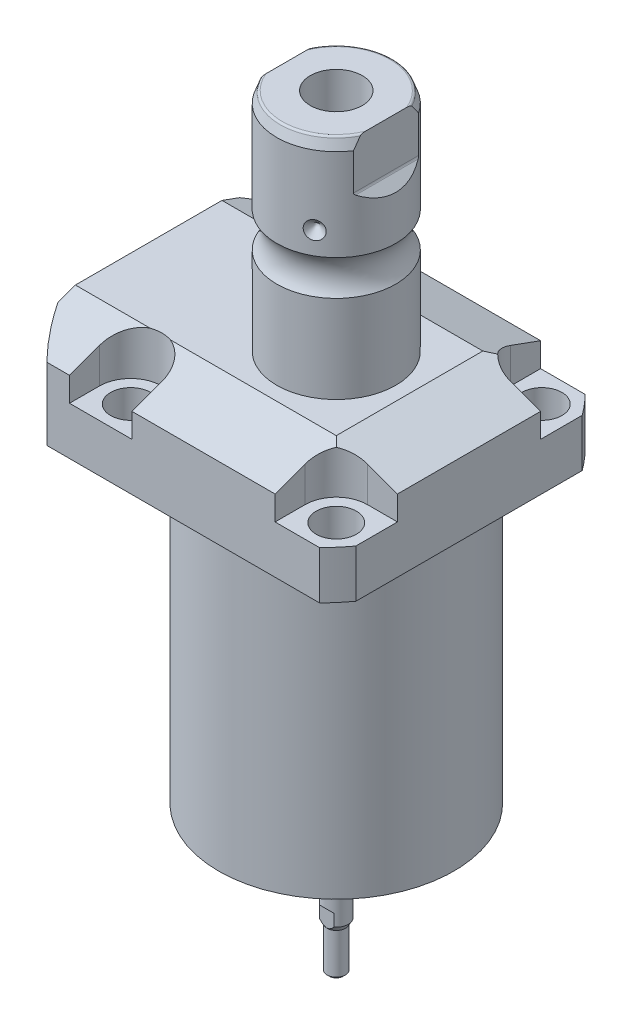
from build123d import *

# Parameters (mm, degrees)
SKETCH1_W                = 70.866
SKETCH1_H                = 85.496
EXTRUDE1_DEPTH           = 104.521
SKETCH2_OUTSIDE_W        = 117.996
SKETCH2_OUTSIDE_H        = 103.366
SKETCH2_OUTSIDE_R        = 50.8
CUT_EXTRUDE1_DEPTH       = 105.521
SKETCH3_W                = 45.1992
SKETCH3_H                = 79.502
FILLET1_R                = 0.381
CUT_EXTRUDE2_DEPTH       = 12.243
CUT_EXTRUDE9_START       = -51.063
CUT_EXTRUDE9_DEPTH       = 87.496
CUT_EXTRUDE7_DEPTH       = 36.433
CUT_EXTRUDE7_DEPTH_BACK  = 36.433
SKETCH10_R               = 1.1811
SKETCH17_W               = 5.3594
SKETCH17_H               = 12.776
HOLE1_AT_2_COUNT         = 2
HOLE1_AT_2_PITCH         = 54.864
HOLE1_AT_3_COUNT         = 2
HOLE1_AT_3_PITCH         = 77.589412886
HOLE1_AT_4_COUNT         = 2
HOLE1_AT_4_PITCH         = 54.864
CHAMFER1_SIZE            = 0.635
FILLET2_R                = 0.635
CIRPATTERN1_COUNT        = 3
CUT_EXTRUDE10_DEPTH      = 36.433
CUT_EXTRUDE10_DEPTH_BACK = 36.433
CUT_EXTRUDE11_DEPTH      = 3.81000762
SKETCH34_W               = 2.70510541
SKETCH34_H               = 1.320802642
SKETCH35_R               = 1.27000254
CUT_EXTRUDE12_DEPTH      = 7.62001524


with BuildPart() as part:
    # Sketch1 → Extrude1 (new body)
    with BuildSketch(Plane(origin=(0, 0, 0), x_dir=(0, 0, 1), z_dir=(0, -1, 0))):
        with Locations((0, 7.315)):
            Rectangle(SKETCH1_W, SKETCH1_H)
    extrude(amount=-EXTRUDE1_DEPTH)

    # Sketch2 outside → Cut-Extrude1 (cut, through all)
    with BuildSketch(Plane.XZ):
        with Locations((-7.315, 0)):
            Rectangle(SKETCH2_OUTSIDE_W, SKETCH2_OUTSIDE_H)
        with Locations((-5.4102, 0)):
            Circle(SKETCH2_OUTSIDE_R, mode=Mode.SUBTRACT)
    extrude(amount=-CUT_EXTRUDE1_DEPTH, mode=Mode.SUBTRACT)

    # Sketch3 → Cut-Revolve1 (revolve, cut)
    with BuildSketch(Plane(origin=(0, 0, 0), x_dir=(0, 0, -1), z_dir=(1, 0, 0))):
        with Locations((53.9941, 39.751)):
            Rectangle(SKETCH3_W, SKETCH3_H)
    revolve(axis=Axis((0, -93.345, 0), (0, 1, 0)), mode=Mode.SUBTRACT)

    # Fillet1
    fillet1_edges = [part.edges().sort_by_distance(p)[0] for p in [
        (0, 79.502, 31.3945),
    ]]
    fillet(fillet1_edges, radius=FILLET1_R)

    # Sketch4 → Cut-Extrude2 (cut)
    with BuildSketch(Plane(origin=(0, 104.521, 0), x_dir=(-1, 0, 0), z_dir=(0, 1, 0))):
        with BuildLine():
            Line((-19.1008, -35.433), (-19.1008, -27.432))
            ThreePointArc((-19.1008, -27.432), (-21.540951985, -21.540951985), (-27.432, -19.1008))
            Line((-27.432, -19.1008), (-35.433, -19.1008))
            Line((-35.433, -19.1008), (-35.433, -35.433))
            Line((-35.433, -35.433), (-19.1008, -35.433))
        make_face()
        with BuildLine():
            Line((35.7632, -35.433), (19.1008, -35.433))
            Line((19.1008, -35.433), (19.1008, -27.432))
            ThreePointArc((19.1008, -27.432), (27.432, -19.1008), (35.7632, -27.432))
            Line((35.7632, -27.432), (35.7632, -35.433))
        make_face()
        with BuildLine():
            Line((19.1008, 35.433), (19.1008, 27.432))
            ThreePointArc((19.1008, 27.432), (27.432, 19.1008), (35.7632, 27.432))
            Line((35.7632, 27.432), (35.7632, 35.433))
            Line((35.7632, 35.433), (19.1008, 35.433))
        make_face()
        with BuildLine():
            Line((-27.432, 19.1008), (-35.433, 19.1008))
            Line((-35.433, 19.1008), (-35.433, 35.433))
            Line((-35.433, 35.433), (-19.1008, 35.433))
            Line((-19.1008, 35.433), (-19.1008, 27.432))
            ThreePointArc((-19.1008, 27.432), (-21.540951985, 21.540951985), (-27.432, 19.1008))
        make_face()
    extrude(amount=-CUT_EXTRUDE2_DEPTH, mode=Mode.SUBTRACT)

    # Sketch5 → Cut-Extrude9 (cut)
    with BuildSketch(Plane(origin=(0, 0, 0), x_dir=(0, 0, -1), z_dir=(1, 0, 0)).offset(CUT_EXTRUDE9_START)):
        Polygon((-19.558, 104.521), (-35.433, 98.742972531), (-35.433, 104.521), align=None)
    cut_extrude9 = extrude(amount=CUT_EXTRUDE9_DEPTH, mode=Mode.SUBTRACT)

    # Mirror1: Cut-Extrude9 across plane
    add(cut_extrude9.mirror(Plane.XY), mode=Mode.SUBTRACT)

    # Sketch9 → Cut-Extrude7 (cut, two sides)
    with BuildSketch(Plane.XY) as cut_extrude7_sk:
        Polygon((19.558, 104.521), (35.433, 98.742972531), (35.433, 104.521), align=None)
    extrude(amount=CUT_EXTRUDE7_DEPTH, mode=Mode.SUBTRACT)
    extrude(cut_extrude7_sk.sketch, amount=-CUT_EXTRUDE7_DEPTH_BACK, mode=Mode.SUBTRACT)

    # Sketch20 → Cut-Revolve4 (revolve, cut)
    with BuildSketch(Plane(origin=(-35.0774, 88.9, -18.1102), x_dir=(0, 1, 0), z_dir=(1, 0, 0)), mode=Mode.PRIVATE) as cut_revolve4_sk:
        Polygon((-9.398, 38.3413), (-7.9502, 38.3413), (-7.9502, 35.8902), (-6.9342, 35.8902), (-6.9342, 33.8836), (4.0386, 33.8836), (4.0386, 32.639), (-9.398, 32.639), align=None)
    cut_revolve4 = revolve(cut_revolve4_sk.sketch.rotate(Axis((-35.0774, 81.620304954, 14.5288), (0, 1, 0)), 180), axis=Axis((-35.0774, 81.620304954, 14.5288), (0, 1, 0)), mode=Mode.SUBTRACT)  # turned: the seam where the file's is

    # Mirror10: Cut-Revolve4 across plane
    add(cut_revolve4.mirror(Plane.XY), mode=Mode.SUBTRACT)

    # Sketch15 → Revolve3 (revolve)
    with BuildSketch(Plane(origin=(0, 0, 0), x_dir=(0, 0, -1), z_dir=(1, 0, 0)), mode=Mode.PRIVATE) as revolve3_sk:
        with BuildLine():
            Line((0, 104.521), (15.875, 104.521))
            Line((15.875, 104.521), (15.875, 127.90590643))
            ThreePointArc((15.875, 127.90590643), (14.3256, 132.613), (15.875, 137.32009357))
            Line((15.875, 137.32009357), (15.875, 161.79799416))
            Line((15.875, 161.79799416), (14.81184082, 164.719))
            Line((14.81184082, 164.719), (0, 164.719))
            Line((0, 164.719), (0, 104.521))
        make_face()
    revolve(revolve3_sk.sketch.rotate(Axis((0, 250.290824608, 0), (0, -1, 0)), 180), axis=Axis((0, 250.290824608, 0), (0, -1, 0)))  # turned: the seam where the file's is

    # Sketch17 → Hole1 (revolve, cut)
    with BuildSketch(Plane(origin=(27.432, 92.278, -27.432), x_dir=(0, 0, 1), z_dir=(1, 0, 0))):
        with Locations((2.6797, 6.388)):
            Rectangle(SKETCH17_W, SKETCH17_H)
    hole1 = revolve(axis=Axis((27.432, -17.722, -27.432), (0, 1, 0)), mode=Mode.SUBTRACT)

    # Hole1 at 2: Hole1 ×2
    with Locations(*[(0, 0, i * HOLE1_AT_2_PITCH) for i in range(1, HOLE1_AT_2_COUNT)]):
        add(hole1, mode=Mode.SUBTRACT)

    # Hole1 at 3: Hole1 ×2
    with Locations(*[Vector(-0.707106781, 0, 0.707106781) * (i * HOLE1_AT_3_PITCH) for i in range(1, HOLE1_AT_3_COUNT)]):
        add(hole1, mode=Mode.SUBTRACT)

    # Hole1 at 4: Hole1 ×2
    with Locations(*[(-i * HOLE1_AT_4_PITCH, 0, 0) for i in range(1, HOLE1_AT_4_COUNT)]):
        add(hole1, mode=Mode.SUBTRACT)

    # Chamfer1
    chamfer1_edges = [part.edges().sort_by_distance(p)[0] for p in [
        (-35.0774, 81.9658, 15.7734),
        (-35.0774, 81.9658, -15.7734),
    ]]
    chamfer(chamfer1_edges, length=CHAMFER1_SIZE)

    # Sketch21 → Cut-Revolve5 (revolve, cut)
    with BuildSketch(Plane.XZ.offset(-92.5068)):
        Polygon((-50.063, -1.9304), (-49.809, -1.9304), (-49.809, -6.3246), (-49.0978, -7.0358), (-35.6358, -7.0358), (-35.6358, -12.9794), (-50.063, -12.9794), align=None)
    cut_revolve5 = revolve(axis=Axis((-57.549532301, 92.5068, -12.9794), (1, 0, 0)), mode=Mode.SUBTRACT)

    # Mirror13: Cut-Revolve5 across plane
    add(cut_revolve5.mirror(Plane.XY), mode=Mode.SUBTRACT)

    # Fillet2
    fillet2_edges = [part.edges().sort_by_distance(p)[0] for p in [
        (0, 164.719, -14.81184082),
    ]]
    fillet(fillet2_edges, radius=FILLET2_R)

    # Sketch26 → Cut-Revolve7 (revolve, cut)
    with BuildSketch(Plane.XY, mode=Mode.PRIVATE) as cut_revolve7_sk:
        Polygon((-15.875, 145.714), (-13.462, 143.301), (-15.875, 143.301), align=None)
    cut_revolve7 = revolve(cut_revolve7_sk.sketch.rotate(Axis((-39.772000707, 143.301, 0), (1, 0, 0)), 90), axis=Axis((-39.772000707, 143.301, 0), (1, 0, 0)), mode=Mode.SUBTRACT)  # turned: the seam where the file's is

    # CirPattern1: Cut-Revolve7 ×3 about axis
    cirpattern1_axis = Axis((0, 250.290824608, 0), (0, 1, 0))
    for i in range(1, CIRPATTERN1_COUNT):
        add(cut_revolve7.rotate(cirpattern1_axis, i * 360 / CIRPATTERN1_COUNT), mode=Mode.SUBTRACT)

    # Sketch27 → Hole2 (revolve, cut)
    with BuildSketch(Plane(origin=(0, 164.719, 0), x_dir=(0, 0, 1), z_dir=(1, 0, 0))):
        Polygon((0, 0), (0, 29.566487704), (6.9342, 25.4), (6.9342, 0), align=None)
    revolve(axis=Axis((0, 168.963199587, 0), (0, -1, 0)), mode=Mode.SUBTRACT)

    # Sketch29 → Cut-Extrude10 (cut, two sides)
    with BuildSketch(Plane.XY) as cut_extrude10_sk:
        with BuildLine():
            Line((13.284, 164.719), (13.284, 152.019))
            ThreePointArc((13.284, 152.019), (13.342003912, 151.727394643), (13.507185078, 151.480183558))
            Line((13.507185078, 151.480183558), (15.875, 149.112368636))
            Line((15.875, 149.112368636), (15.875, 164.719))
            Line((15.875, 164.719), (13.284, 164.719))
        make_face()
        with BuildLine():
            Line((-15.875, 164.719), (-13.284, 164.719))
            Line((-13.284, 164.719), (-13.284, 152.019))
            ThreePointArc((-13.284, 152.019), (-13.342003912, 151.727394643), (-13.507185078, 151.480183558))
            Line((-13.507185078, 151.480183558), (-15.875, 149.112368636))
            Line((-15.875, 149.112368636), (-15.875, 164.719))
        make_face()
    extrude(amount=CUT_EXTRUDE10_DEPTH, mode=Mode.SUBTRACT)
    extrude(cut_extrude10_sk.sketch, amount=-CUT_EXTRUDE10_DEPTH_BACK, mode=Mode.SUBTRACT)

    # Sketch30 → Revolve5 (revolve)
    with BuildSketch(Plane(origin=(0, 0, 0), x_dir=(0, 0, -1), z_dir=(1, 0, 0)), mode=Mode.PRIVATE) as revolve5_sk:
        Polygon((0, 0), (3.17500635, 0), (3.17500635, -26.410553634), (2.438404877, -27.686384811), (2.438404877, -38.481406401), (1.803403607, -39.116407671), (0, -39.116407671), align=None)
    revolve(revolve5_sk.sketch.rotate(Axis((0, -1000, 0), (0, 1, 0)), 180), axis=Axis((0, -1000, 0), (0, 1, 0)))  # turned: the seam where the file's is

    # Sketch33 → Cut-Extrude11 (cut, symmetric)
    with BuildSketch(Plane(origin=(0, 0, 0), x_dir=(0, 0, -1), z_dir=(1, 0, 0))):
        Polygon((2.501905004, -39.116407671), (2.501905004, -23.241375921), (3.17500635, -22.568274575), (3.17500635, -39.116407671), align=None)
        Polygon((-3.17500635, -39.116407671), (-2.501905004, -39.116407671), (-2.501905004, -23.241375921), (-3.17500635, -22.568274575), align=None)
    extrude(amount=CUT_EXTRUDE11_DEPTH, both=True, mode=Mode.SUBTRACT)

    # Sketch34 → Cut-Revolve8 (revolve, cut)
    with BuildSketch(Plane(origin=(0, 0, 0), x_dir=(0, 0, -1), z_dir=(1, 0, 0)), mode=Mode.PRIVATE) as cut_revolve8_sk:
        with Locations((12.998475997, 0.660401321)):
            Rectangle(SKETCH34_W, SKETCH34_H)
    revolve(cut_revolve8_sk.sketch.rotate(Axis((0, -1000, 0), (0, 1, 0)), 218.00100076), axis=Axis((0, -1000, 0), (0, 1, 0)), mode=Mode.SUBTRACT)  # turned: the seam where the file's is

    # Sketch35 → Cut-Extrude12 (cut)
    with BuildSketch(Plane.XZ):
        with Locations(Location((19.431038862, 0, 0), (0, 0, 270))):  # turned: the seam where the file's is
            Circle(SKETCH35_R)
        with Locations(Location((18.768942269, -5.029122924, 0), (0, 0, 270))):  # turned: the seam where the file's is
            Circle(SKETCH35_R)
        with Locations(Location((-13.739819345, 13.739819345, 0), (0, 0, 90))):  # turned: the seam where the file's is
            Circle(SKETCH35_R)
        with Locations(Location((-9.715519431, 16.827773276, 0), (0, 0, 90))):  # turned: the seam where the file's is
            Circle(SKETCH35_R)
        with Locations(Location((-13.739819345, -13.739819345, 0), (0, 0, 270))):  # turned: the seam where the file's is
            Circle(SKETCH35_R)
        with Locations(Location((-9.715519431, -16.827773276, 0), (0, 0, 270))):  # turned: the seam where the file's is
            Circle(SKETCH35_R)
    extrude(amount=-CUT_EXTRUDE12_DEPTH, mode=Mode.SUBTRACT)


with BuildPart() as body_2:
    # Sketch10 → Revolve4 (revolve)
    with BuildSketch(Plane(origin=(-35.0774, 88.9, -18.1102), x_dir=(0, 1, 0), z_dir=(1, 0, 0))):
        with Locations((-9.1313, 8.1026)):
            Circle(SKETCH10_R)
    revolve(axis=Axis((-35.0774, 87.86749, -14.5288), (0, 1, 0)))


with BuildPart() as body_3:
    # Mirror12: mirrored copy
    add(body_2.part.mirror(Plane.XY))


solid = Compound([part.part, body_2.part, body_3.part])
